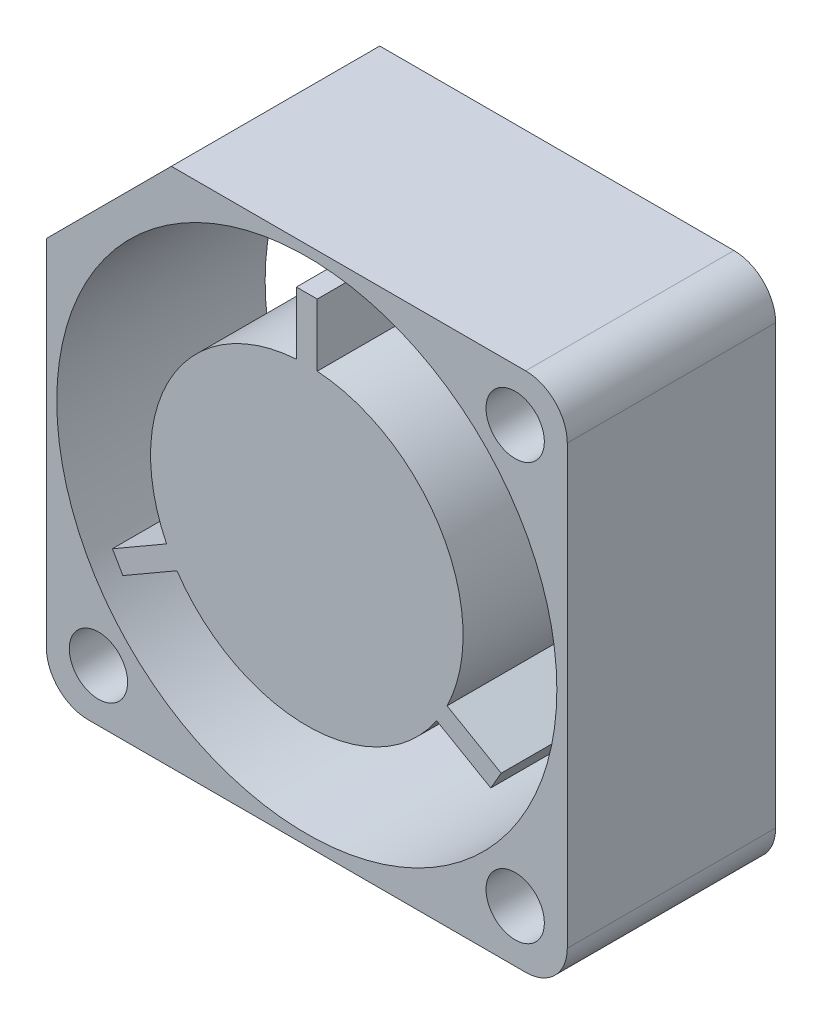
from build123d import *

# Parameters (mm, degrees)
SKETCH1_W                = 25
SKETCH1_H                = 25
SKETCH1_R                = 1.4
SKETCH1_R_2              = 12
BOSS_EXTRUDE1_DEPTH      = 5
BOSS_EXTRUDE1_DEPTH_BACK = 5
FILLET1_R                = 2
BOSS_EXTRUDE2_DEPTH      = 10
CUT_EXTRUDE1_DEPTH       = 11


with BuildPart() as part:
    # Sketch1 → Boss-Extrude1 (new body, two sides)
    with BuildSketch(Plane.XY) as boss_extrude1_sk:
        Rectangle(SKETCH1_W, SKETCH1_H)
        with Locations((10, 10)):
            Circle(SKETCH1_R, mode=Mode.SUBTRACT)
        with Locations((10, -10)):
            Circle(SKETCH1_R, mode=Mode.SUBTRACT)
        with Locations((-10, -10)):
            Circle(SKETCH1_R, mode=Mode.SUBTRACT)
        Circle(SKETCH1_R_2, mode=Mode.SUBTRACT)
    extrude(amount=BOSS_EXTRUDE1_DEPTH)
    extrude(boss_extrude1_sk.sketch, amount=-BOSS_EXTRUDE1_DEPTH_BACK)

    # Fillet1
    fillet1_edges = [part.edges().sort_by_distance(p)[0] for p in [
        (-12.5, 12.5, 0),
        (12.5, 12.5, 0),
        (12.5, -12.5, 0),
        (-12.5, -12.5, 0),
    ]]
    fillet(fillet1_edges, radius=FILLET1_R)

    # Sketch3 → Cut-Extrude1 (cut, through all)
    with BuildSketch(Plane.XY.offset(5)):
        with BuildLine():
            Line((-6.5, 12.5), (-12.5, 6.5))
            Line((-12.5, 6.5), (-12.5, 10.5))
            ThreePointArc((-12.5, 10.5), (-11.914213562, 11.914213562), (-10.5, 12.5))
            Line((-10.5, 12.5), (-6.5, 12.5))
        make_face()
    extrude(amount=-CUT_EXTRUDE1_DEPTH, mode=Mode.SUBTRACT)


with BuildPart() as body_2:
    # Sketch2 → Boss-Extrude2 (new body)
    with BuildSketch(Plane.XY.offset(5)):
        with BuildLine():
            Line((-6.730740698, -3.308644685), (-9.32881691, -4.808644685))
            Line((-9.32881691, -4.808644685), (-8.82881691, -5.674670089))
            Line((-8.82881691, -5.674670089), (-6.230740698, -4.174670089))
            ThreePointArc((-6.230740698, -4.174670089), (0, -7.5), (6.230740698, -4.174670089))
            Line((6.230740698, -4.174670089), (8.82881691, -5.674670089))
            Line((8.82881691, -5.674670089), (9.32881691, -4.808644685))
            Line((9.32881691, -4.808644685), (6.730740698, -3.308644685))
            ThreePointArc((6.730740698, -3.308644685), (6.495190528, 3.75), (0.5, 7.483314774))
            Line((0.5, 7.483314774), (0.5, 10.483314774))
            Line((0.5, 10.483314774), (-0.5, 10.483314774))
            Line((-0.5, 10.483314774), (-0.5, 7.483314774))
            ThreePointArc((-0.5, 7.483314774), (-6.495190528, 3.75), (-6.730740698, -3.308644685))
        make_face()
    extrude(amount=-BOSS_EXTRUDE2_DEPTH)


solid = Compound([part.part, body_2.part])
